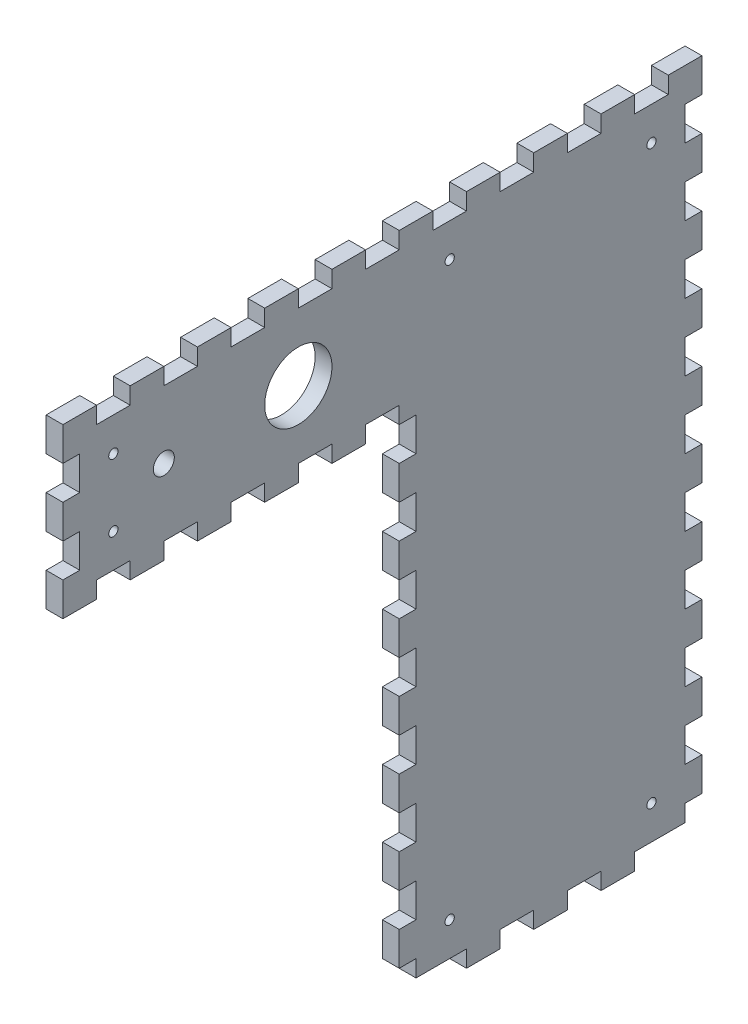
from build123d import *

# Parameters (mm, degrees)
SKETCH1_R           = 1.75
BOSS_EXTRUDE1_DEPTH = 6.35
SKETCH2_W           = 12.7
SKETCH2_H           = 6.35
CUT_EXTRUDE1_DEPTH  = 7.35
LPATTERN1_COUNT     = 10
LPATTERN1_PITCH     = 25.4
SKETCH3_W           = 6.35
SKETCH3_H           = 12.7
CUT_EXTRUDE2_DEPTH  = 7.35
LPATTERN2_COUNT     = 10
LPATTERN2_PITCH     = 25.4
SKETCH4_W           = 6.35
SKETCH4_H           = 12.7
CUT_EXTRUDE3_DEPTH  = 7.35
SKETCH5_W           = 12.7
SKETCH5_H           = 6.35
CUT_EXTRUDE4_DEPTH  = 7.35
LPATTERN3_COUNT     = 5
LPATTERN3_PITCH     = 25.4
SKETCH6_W           = 6.35
SKETCH6_H           = 12.7
CUT_EXTRUDE5_DEPTH  = 7.35
LPATTERN4_COUNT     = 8
LPATTERN4_PITCH     = 25.4
SKETCH7_W           = 12.7
SKETCH7_H           = 6.35
CUT_EXTRUDE6_DEPTH  = 7.35
SKETCH8_W           = 6.35
SKETCH8_H           = 6.35
CUT_EXTRUDE7_DEPTH  = 7.35
SKETCH9_R           = 3.96875
CUT_EXTRUDE8_DEPTH  = 7.35
SKETCH10_R          = 12.7
CUT_EXTRUDE9_DEPTH  = 7.35


with BuildPart() as part:
    # Sketch1 → Boss-Extrude1 (new body)
    with BuildSketch(Plane(origin=(0, 0, 0), x_dir=(0, 0, -1), z_dir=(1, 0, 0))):
        Polygon((0, 0), (0, 190.5), (-127, 190.5), (-127, 254), (114.3, 254), (114.3, 0), align=None)
        with Locations((-107.95, 234.95)):
            Circle(SKETCH1_R, mode=Mode.SUBTRACT)
        with Locations((-107.95, 209.55)):
            Circle(SKETCH1_R, mode=Mode.SUBTRACT)
        with Locations((19.05, 234.95)):
            Circle(SKETCH1_R, mode=Mode.SUBTRACT)
        with Locations((95.25, 234.95)):
            Circle(SKETCH1_R, mode=Mode.SUBTRACT)
        with Locations((19.05, 19.05)):
            Circle(SKETCH1_R, mode=Mode.SUBTRACT)
        with Locations((95.25, 19.05)):
            Circle(SKETCH1_R, mode=Mode.SUBTRACT)
    extrude(amount=BOSS_EXTRUDE1_DEPTH)

    # Sketch2 → Cut-Extrude1 (cut, through all)
    with BuildSketch(Plane(origin=(6.35, 0, 0), x_dir=(0, 0, -1), z_dir=(1, 0, 0))):
        with Locations((-107.95, 250.825)):
            Rectangle(SKETCH2_W, SKETCH2_H)
    cut_extrude1 = extrude(amount=-CUT_EXTRUDE1_DEPTH, mode=Mode.SUBTRACT)

    # LPattern1: Cut-Extrude1 ×10
    with Locations(*[(0, 0, -i * LPATTERN1_PITCH) for i in range(1, LPATTERN1_COUNT)]):
        add(cut_extrude1, mode=Mode.SUBTRACT)

    # Sketch3 → Cut-Extrude2 (cut, through all)
    with BuildSketch(Plane(origin=(6.35, 0, 0), x_dir=(0, 0, -1), z_dir=(1, 0, 0))):
        with Locations((111.125, 234.95)):
            Rectangle(SKETCH3_W, SKETCH3_H)
    cut_extrude2 = extrude(amount=-CUT_EXTRUDE2_DEPTH, mode=Mode.SUBTRACT)

    # LPattern2: Cut-Extrude2 ×10
    with Locations(*[(0, -i * LPATTERN2_PITCH, 0) for i in range(1, LPATTERN2_COUNT)]):
        add(cut_extrude2, mode=Mode.SUBTRACT)

    # Sketch4 → Cut-Extrude3 (cut, through all)
    with BuildSketch(Plane(origin=(6.35, 0, 0), x_dir=(0, 0, -1), z_dir=(1, 0, 0))):
        with Locations((-123.825, 234.95)):
            Rectangle(SKETCH4_W, SKETCH4_H)
        with Locations((-123.825, 209.55)):
            Rectangle(SKETCH4_W, SKETCH4_H)
    extrude(amount=-CUT_EXTRUDE3_DEPTH, mode=Mode.SUBTRACT)

    # Sketch5 → Cut-Extrude4 (cut, through all)
    with BuildSketch(Plane(origin=(6.35, 0, 0), x_dir=(0, 0, -1), z_dir=(1, 0, 0))):
        with Locations((-107.95, 193.675)):
            Rectangle(SKETCH5_W, SKETCH5_H)
    cut_extrude4 = extrude(amount=-CUT_EXTRUDE4_DEPTH, mode=Mode.SUBTRACT)

    # LPattern3: Cut-Extrude4 ×5
    with Locations(*[(0, 0, -i * LPATTERN3_PITCH) for i in range(1, LPATTERN3_COUNT)]):
        add(cut_extrude4, mode=Mode.SUBTRACT)

    # Sketch6 → Cut-Extrude5 (cut, through all)
    with BuildSketch(Plane(origin=(6.35, 0, 0), x_dir=(0, 0, -1), z_dir=(1, 0, 0))):
        with Locations((3.175, 6.35)):
            Rectangle(SKETCH6_W, SKETCH6_H)
    cut_extrude5 = extrude(amount=-CUT_EXTRUDE5_DEPTH, mode=Mode.SUBTRACT)

    # LPattern4: Cut-Extrude5 ×8
    with Locations(*[(0, i * LPATTERN4_PITCH, 0) for i in range(1, LPATTERN4_COUNT)]):
        add(cut_extrude5, mode=Mode.SUBTRACT)

    # Sketch7 → Cut-Extrude6 (cut, through all)
    with BuildSketch(Plane(origin=(6.35, 0, 0), x_dir=(0, 0, -1), z_dir=(1, 0, 0))):
        with Locations((19.05, 3.175)):
            Rectangle(SKETCH7_W, SKETCH7_H)
        with Locations((44.45, 3.175)):
            Rectangle(SKETCH7_W, SKETCH7_H)
        with Locations((69.85, 3.175)):
            Rectangle(SKETCH7_W, SKETCH7_H)
        with Locations((95.25, 3.175)):
            Rectangle(SKETCH7_W, SKETCH7_H)
    extrude(amount=-CUT_EXTRUDE6_DEPTH, mode=Mode.SUBTRACT)

    # Sketch8 → Cut-Extrude7 (cut, through all)
    with BuildSketch(Plane(origin=(6.35, 0, 0), x_dir=(0, 0, -1), z_dir=(1, 0, 0))):
        with Locations((9.525, 3.175)):
            Rectangle(SKETCH8_W, SKETCH8_H)
        with Locations((104.775, 3.175)):
            Rectangle(SKETCH8_W, SKETCH8_H)
    extrude(amount=-CUT_EXTRUDE7_DEPTH, mode=Mode.SUBTRACT)

    # Sketch9 → Cut-Extrude8 (cut, through all)
    with BuildSketch(Plane(origin=(6.35, 0, 0), x_dir=(0, 0, -1), z_dir=(1, 0, 0))):
        with Locations((-88.9, 222.25)):
            Circle(SKETCH9_R)
    extrude(amount=-CUT_EXTRUDE8_DEPTH, mode=Mode.SUBTRACT)

    # Sketch10 → Cut-Extrude9 (cut, through all)
    with BuildSketch(Plane(origin=(6.35, 0, 0), x_dir=(0, 0, -1), z_dir=(1, 0, 0))):
        with Locations((-38.1, 222.25)):
            Circle(SKETCH10_R)
    extrude(amount=-CUT_EXTRUDE9_DEPTH, mode=Mode.SUBTRACT)


solid = part.part
